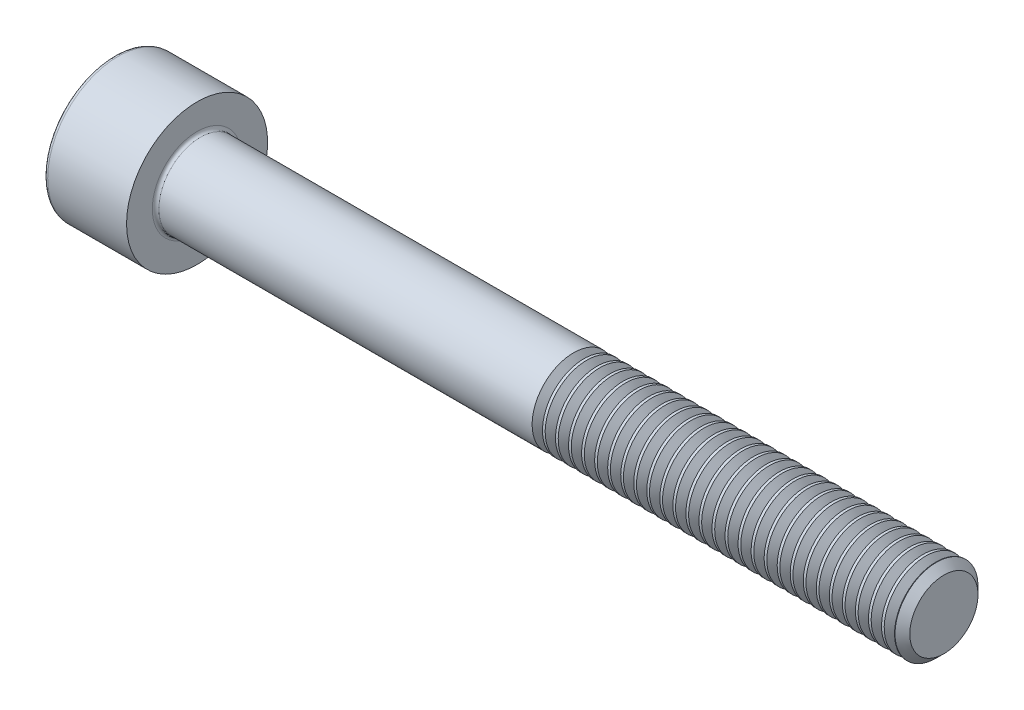
from build123d import *

# Parameters (mm, degrees)
FILLET1_R       = 0.2
FILLET2_R       = 0.25
HEX_2_DEPTH     = 2.5
THDSCHPAT_COUNT = 29
THDSCHPAT_PITCH = 0.785714286


with BuildPart() as part:
    # BodySke → Base-Revolve (revolve)
    with BuildSketch(Plane.XY):
        Polygon((0, 0), (0, 4.25), (5, 4.25), (5, 2.5), (49.555, 2.5), (50, 2.055), (50, 0), align=None)
    revolve(axis=Axis((-31.75, 0, 0), (1, 0, 0)))

    # Fillet1
    fillet1_edges = [part.edges().sort_by_distance(p)[0] for p in [
        (5, -2.5, 0),
    ]]
    fillet(fillet1_edges, radius=FILLET1_R)

    # Fillet2
    fillet2_edges = [part.edges().sort_by_distance(p)[0] for p in [
        (0, -4.25, 0),
    ]]
    fillet(fillet2_edges, radius=FILLET2_R)

    # Sketch2 → Hex-PreBroach (revolve, cut)
    with BuildSketch(Plane.XY):
        Polygon((0, 2.042), (2.5, 2.042), (3.67894925, 0), (0, 0), align=None)
    revolve(axis=Axis((0, 0, 0), (1, 0, 0)), mode=Mode.SUBTRACT)

    # Sketch3 → Hex 2 (cut)
    with BuildSketch(Plane(origin=(0, 0, 0), x_dir=(0, 0.5, 0.866025404), z_dir=(-1, 0, 0))):
        Polygon((1.17894925, 2.042), (-1.17894925, 2.042), (-2.357898499, 0), (-1.17894925, -2.042), (1.17894925, -2.042), (2.357898499, 0), align=None)
    extrude(amount=-HEX_2_DEPTH, mode=Mode.SUBTRACT)

    # ThdSchSke → ThreadSchematic (revolve, cut)
    with BuildSketch(Plane.XY):
        Polygon((28, -2.055), (27.688407645, -2.5), (27.688407645, -3.125), (28.311592355, -3.125), (28.311592355, -2.5), align=None)
    threadschematic = revolve(axis=Axis((-3.175, 0, 0), (1, 0, 0)), mode=Mode.SUBTRACT)

    # ThdSchPat: ThreadSchematic ×29
    with Locations(*[(i * THDSCHPAT_PITCH, 0, 0) for i in range(1, THDSCHPAT_COUNT)]):
        add(threadschematic, mode=Mode.SUBTRACT)


solid = part.part
